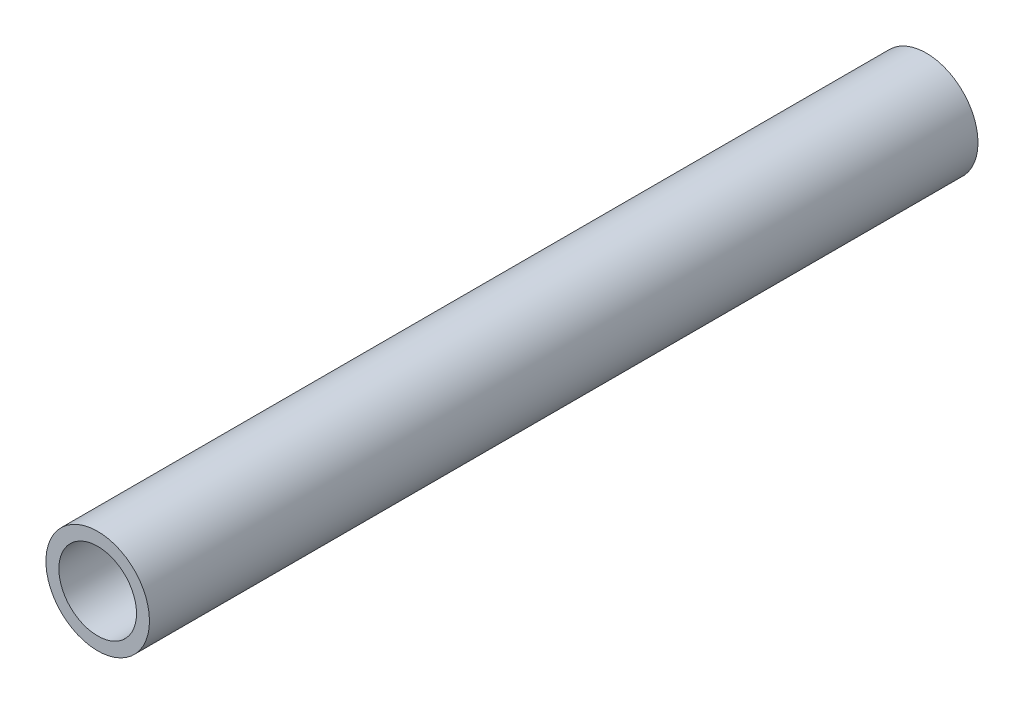
from build123d import *

# Parameters (mm, degrees)
SKETCH1_R           = 3.175
SKETCH1_R_2         = 2.38125
BOSS_EXTRUDE1_DEPTH = 50.8


with BuildPart() as part:
    # Sketch1 → Boss-Extrude1 (new body)
    with BuildSketch(Plane.XY):
        Circle(SKETCH1_R)
        Circle(SKETCH1_R_2, mode=Mode.SUBTRACT)
    extrude(amount=BOSS_EXTRUDE1_DEPTH)


solid = part.part
